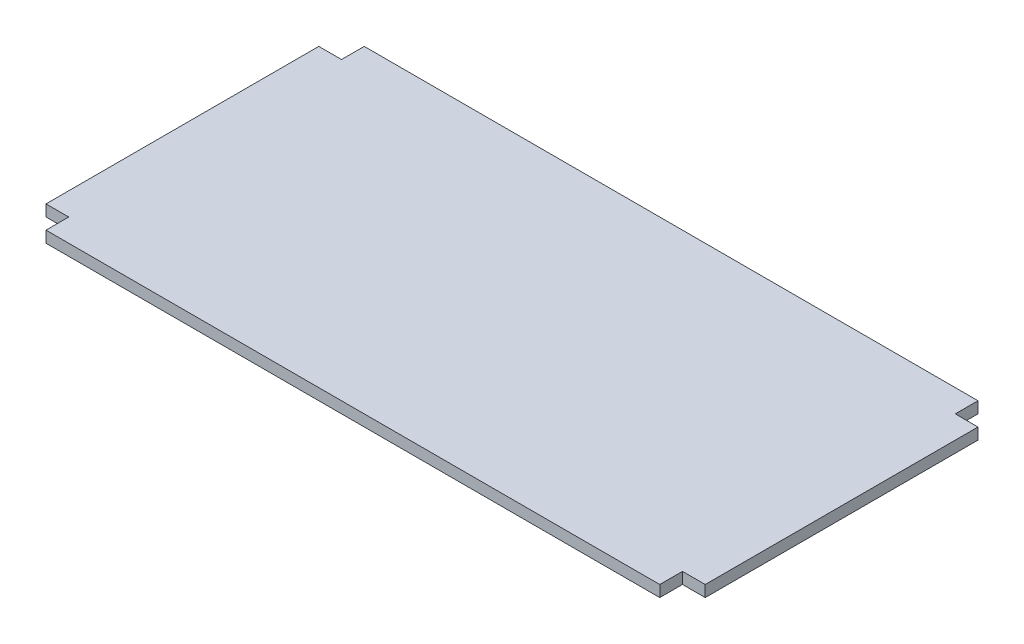
from build123d import *

# Parameters (mm, degrees)
BOSS_EXTRUDE1_DEPTH = 12.7
SKETCH2_W           = 12.7
SKETCH2_H           = 304.8
SKETCH2_W_2         = 685.8
SKETCH2_H_2         = 12.7
CUT_EXTRUDE1_DEPTH  = 12.7


with BuildPart() as part:
    # Sketch1 → Boss-Extrude1 (new body)
    with BuildSketch(Plane(origin=(0, 0, 0), x_dir=(1, 0, 0), z_dir=(0, 1, 0))):
        Polygon((342.9, 190.5), (-342.9, 190.5), (-342.9, 152.4), (-381, 152.4), (-381, -152.4), (-342.9, -152.4), (-342.9, -190.5), (342.9, -190.5), (342.9, -152.4), (381, -152.4), (381, 152.4), (342.9, 152.4), align=None)
    extrude(amount=BOSS_EXTRUDE1_DEPTH)

    # Sketch2 → Cut-Extrude1 (cut)
    with BuildSketch(Plane(origin=(0, 12.7, 0), x_dir=(1, 0, 0), z_dir=(0, 1, 0))):
        with Locations((-374.65, 0)):
            Rectangle(SKETCH2_W, SKETCH2_H)
        with Locations((0, 184.15)):
            Rectangle(SKETCH2_W_2, SKETCH2_H_2)
        with Locations((374.65, 0)):
            Rectangle(SKETCH2_W, SKETCH2_H)
        with Locations((0, -184.15)):
            Rectangle(SKETCH2_W_2, SKETCH2_H_2)
    extrude(amount=-CUT_EXTRUDE1_DEPTH, mode=Mode.SUBTRACT)


solid = part.part
